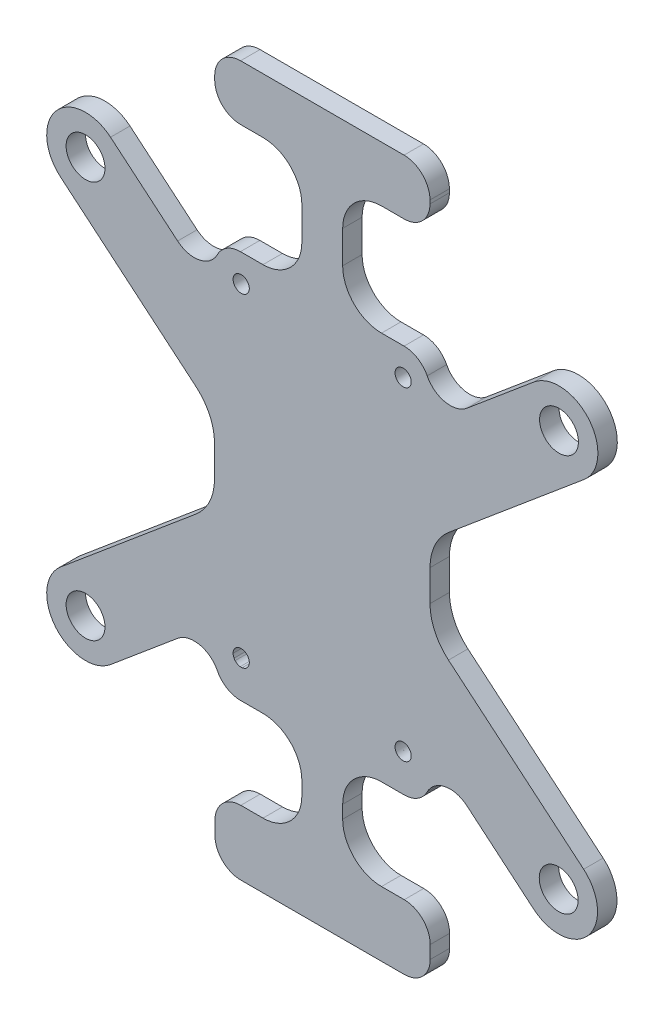
from build123d import *

# Parameters (mm, degrees)
SKETCH2_R           = 3
BOSS_EXTRUDE1_DEPTH = 3
FILLET1_R           = 4


with BuildPart() as part:
    # Sketch2 → Boss-Extrude1 (new body)
    with BuildSketch(Plane(origin=(0, 0, 68.235245174), x_dir=(-1, 0, 0), z_dir=(0, 0, -1))):
        with BuildLine():
            ThreePointArc((200.8599001, 75.914500352), (202.617259412, 80.157141039), (206.8599001, 81.914500352))
            Line((206.8599001, 81.914500352), (210.318399578, 81.914500352))
            ThreePointArc((210.318399578, 81.914500352), (213.146826703, 83.086073227), (214.318399578, 85.914500352))
            Line((214.318399578, 85.914500352), (214.318399578, 86.448569062))
            ThreePointArc((214.318399578, 86.448569062), (213.146826703, 89.276996187), (210.318399578, 90.448569062))
            Line((210.318399578, 90.448569062), (185.082704853, 90.448569062))
            ThreePointArc((185.082704853, 90.448569062), (182.254277728, 89.276996187), (181.082704853, 86.448569062))
            Line((181.082704853, 86.448569062), (181.082704853, 85.914500352))
            ThreePointArc((181.082704853, 85.914500352), (182.254277728, 83.086073227), (185.082704853, 81.914500352))
            Line((185.082704853, 81.914500352), (188.558928324, 81.914500352))
            ThreePointArc((188.558928324, 81.914500352), (192.801569011, 80.157141039), (194.558928324, 75.914500352))
            Line((194.558928324, 75.914500352), (194.558928324, 70.914500352))
            ThreePointArc((194.558928324, 70.914500352), (192.801569011, 66.671859665), (188.558928324, 64.914500352))
            Line((188.558928324, 64.914500352), (185.076777298, 64.914500352))
            ThreePointArc((185.076777298, 64.914500352), (182.248350173, 63.742927477), (181.076777298, 60.914500352))
            Line((181.076777298, 60.914500352), (181.076777298, 56.686920612))
            Line((181.076777298, 56.686920612), (165.01232587, 70.156152413))
            ThreePointArc((165.01232587, 70.156152413), (156.559616389, 69.413385675), (157.302383127, 60.960676194))
            Line((157.302383127, 60.960676194), (178.216739127, 43.425044169))
            ThreePointArc((178.216739127, 43.425044169), (180.326594352, 40.677056165), (181.076777298, 37.294726689))
            Line((181.076777298, 37.294726689), (181.076777298, 32.487814398))
            ThreePointArc((181.076777298, 32.487814398), (180.328083004, 29.108677592), (178.222135908, 26.362025896))
            Line((178.222135908, 26.362025896), (157.352338412, 8.832430774))
            ThreePointArc((157.352338412, 8.832430774), (156.617015993, 0.37907044), (165.070376328, -0.356251978))
            Line((165.070376328, -0.356251978), (181.076777298, 13.088331201))
            Line((181.076777298, 13.088331201), (181.076777298, 11.930427072))
            Line((181.076777298, 11.930427072), (181.076777298, 8.914500352))
            ThreePointArc((181.076777298, 8.914500352), (182.248350173, 6.086073227), (185.076777298, 4.914500352))
            Line((185.076777298, 4.914500352), (188.558928324, 4.914500352))
            ThreePointArc((188.558928324, 4.914500352), (192.801569011, 3.157141039), (194.558928324, -1.085499648))
            Line((194.558928324, -1.085499648), (194.558928324, -3.085499648))
            ThreePointArc((194.558928324, -3.085499648), (192.801569011, -7.328140335), (188.558928324, -9.085499648))
            Line((188.558928324, -9.085499648), (185.047198195, -9.085499648))
            ThreePointArc((185.047198195, -9.085499648), (182.21877107, -10.257072523), (181.047198195, -13.085499648))
            Line((181.047198195, -13.085499648), (181.047198195, -15.085499648))
            ThreePointArc((181.047198195, -15.085499648), (182.21877107, -17.913926773), (185.047198195, -19.085499648))
            Line((185.047198195, -19.085499648), (210.282892919, -19.085499648))
            ThreePointArc((210.282892919, -19.085499648), (213.111320044, -17.913926773), (214.282892919, -15.085499648))
            Line((214.282892919, -15.085499648), (214.282892919, -13.085499648))
            ThreePointArc((214.282892919, -13.085499648), (213.111320044, -10.257072523), (210.282892919, -9.085499648))
            Line((210.282892919, -9.085499648), (206.8599001, -9.085499648))
            ThreePointArc((206.8599001, -9.085499648), (202.617259412, -7.328140335), (200.8599001, -3.085499648))
            Line((200.8599001, -3.085499648), (200.8599001, -1.085499648))
            ThreePointArc((200.8599001, -1.085499648), (202.617259412, 3.157141039), (206.8599001, 4.914500352))
            Line((206.8599001, 4.914500352), (210.342051126, 4.914500352))
            ThreePointArc((210.342051126, 4.914500352), (213.170478251, 6.086073227), (214.342051126, 8.914500352))
            Line((214.342051126, 8.914500352), (214.342051126, 11.930427072))
            Line((214.342051126, 11.930427072), (214.342051126, 13.135793187))
            Line((214.342051126, 13.135793187), (230.399402266, -0.32748538))
            ThreePointArc((230.399402266, -0.32748538), (238.852111747, 0.415281358), (238.109345009, 8.867990839))
            Line((238.109345009, 8.867990839), (217.202089297, 26.397669631))
            ThreePointArc((217.202089297, 26.397669631), (215.092234072, 29.145657634), (214.342051126, 32.52798711))
            Line((214.342051126, 32.52798711), (214.342051126, 37.301480569))
            ThreePointArc((214.342051126, 37.301480569), (215.09074542, 40.680617376), (217.196692515, 43.427269071))
            Line((217.196692515, 43.427269071), (238.113392595, 60.996260038))
            ThreePointArc((238.113392595, 60.996260038), (238.848715014, 69.449620372), (230.39535468, 70.184942791))
            Line((230.39535468, 70.184942791), (214.342051126, 56.700963767))
            Line((214.342051126, 56.700963767), (214.342051126, 60.914500352))
            ThreePointArc((214.342051126, 60.914500352), (213.170478251, 63.742927477), (210.342051126, 64.914500352))
            Line((210.342051126, 64.914500352), (206.8599001, 64.914500352))
            ThreePointArc((206.8599001, 64.914500352), (202.617259412, 66.671859665), (200.8599001, 70.914500352))
            Line((200.8599001, 70.914500352), (200.8599001, 75.914500352))
        make_face()
        with Locations((161.21135737, 4.238089398)):
            Circle(SKETCH2_R, mode=Mode.SUBTRACT)
        with BuildLine():
            ThreePointArc((185.934292771, 11.679915797), (186.053113792, 11.586823557), (186.159847502, 11.480087831))
            ThreePointArc((186.159847502, 11.480087831), (186.252935887, 11.361267382), (186.331023692, 11.232092921))
            ThreePointArc((186.331023692, 11.232092921), (186.392973368, 11.09444513), (186.437879802, 10.950333754))
            ThreePointArc((186.437879802, 10.950333754), (186.465087989, 10.801861649), (186.474201683, 10.651192502))
            ThreePointArc((186.474201683, 10.651192502), (186.465087553, 10.500519764), (186.437878071, 10.352044225))
            ThreePointArc((186.437878071, 10.352044225), (186.392969746, 10.207930322), (186.331017561, 10.0702804))
            ThreePointArc((186.331017561, 10.0702804), (186.252930555, 9.941109897), (186.159843804, 9.822292998))
            ThreePointArc((186.159843804, 9.822292998), (186.053110121, 9.715558193), (185.934289288, 9.622466802))
            ThreePointArc((185.934289288, 9.622466802), (185.805115307, 9.544376995), (185.667470605, 9.482426437))
            ThreePointArc((185.667470605, 9.482426437), (185.523353139, 9.43751622), (185.374872981, 9.410305666))
            ThreePointArc((185.374872981, 9.410305666), (185.224200783, 9.401191602), (185.073528586, 9.410305666))
            ThreePointArc((185.073528586, 9.410305666), (184.925061955, 9.437512885), (184.780957016, 9.482416556))
            ThreePointArc((184.780957016, 9.482416556), (184.643309455, 9.544364821), (184.514132464, 9.62245287))
            ThreePointArc((184.514132464, 9.62245287), (184.395308021, 9.715543509), (184.288570868, 9.822278205))
            ThreePointArc((184.288570868, 9.822278205), (184.195478591, 9.941098916), (184.117387224, 10.070274268))
            ThreePointArc((184.117387224, 10.070274268), (184.055433048, 10.207927085), (184.010523496, 10.352044225))
            ThreePointArc((184.010523496, 10.352044225), (183.983314014, 10.500519764), (183.974199884, 10.651192502))
            ThreePointArc((183.974199884, 10.651192502), (183.983313578, 10.801861649), (184.010521765, 10.950333754))
            ThreePointArc((184.010521765, 10.950333754), (184.055429426, 11.094448368), (184.117381092, 11.232099052))
            ThreePointArc((184.117381092, 11.232099052), (184.19547326, 11.361278363), (184.28856717, 11.480102624))
            ThreePointArc((184.28856717, 11.480102624), (184.39530435, 11.586838242), (184.51412898, 11.679929729))
            ThreePointArc((184.51412898, 11.679929729), (184.643306412, 11.758018585), (184.780954545, 11.819967511))
            ThreePointArc((184.780954545, 11.819967511), (184.925059801, 11.864871587), (185.073526803, 11.89207912))
            ThreePointArc((185.073526803, 11.89207912), (185.224200783, 11.901193401), (185.374874764, 11.89207912))
            ThreePointArc((185.374874764, 11.89207912), (185.523355294, 11.864868252), (185.667473076, 11.819957629))
            ThreePointArc((185.667473076, 11.819957629), (185.80511835, 11.758006411), (185.934292771, 11.679915797))
        make_face(mode=Mode.SUBTRACT)
        with Locations((234.254373637, 4.27025273)):
            Circle(SKETCH2_R, mode=Mode.SUBTRACT)
        with BuildLine():
            ThreePointArc((209.010536826, 10.352046042), (208.983327509, 10.500520678), (208.974213434, 10.651192502))
            ThreePointArc((208.974213434, 10.651192502), (208.983327073, 10.801860734), (209.010535095, 10.950331938))
            ThreePointArc((209.010535095, 10.950331938), (209.055441255, 11.094442439), (209.117390555, 11.232089393))
            ThreePointArc((209.117390555, 11.232089393), (209.195480693, 11.361267136), (209.288572259, 11.480090194))
            ThreePointArc((209.288572259, 11.480090194), (209.395307056, 11.586825218), (209.51412916, 11.679916516))
            ThreePointArc((209.51412916, 11.679916516), (209.64331047, 11.758009014), (209.780963197, 11.819960414))
            ThreePointArc((209.780963197, 11.819960414), (209.925067578, 11.864864217), (210.073533678, 11.892071586))
            ThreePointArc((210.073533678, 11.892071586), (210.224206744, 11.901185811), (210.374879809, 11.892071586))
            ThreePointArc((210.374879809, 11.892071586), (210.523352674, 11.86486255), (210.667463317, 11.819955473))
            ThreePointArc((210.667463317, 11.819955473), (210.805109186, 11.758005777), (210.934284327, 11.679916516))
            ThreePointArc((210.934284327, 11.679916516), (211.05311013, 11.586821942), (211.159847781, 11.480082798))
            ThreePointArc((211.159847781, 11.480082798), (211.252935601, 11.36126307), (211.331022932, 11.232089393))
            ThreePointArc((211.331022932, 11.232089393), (211.392972232, 11.094442439), (211.437878393, 10.950331938))
            ThreePointArc((211.437878393, 10.950331938), (211.465086414, 10.801860734), (211.474200053, 10.651192502))
            ThreePointArc((211.474200053, 10.651192502), (211.465085978, 10.500520678), (211.437876661, 10.352046042))
            ThreePointArc((211.437876661, 10.352046042), (211.39296861, 10.207933014), (211.3310168, 10.070283927))
            ThreePointArc((211.3310168, 10.070283927), (211.252930269, 9.941114209), (211.159844083, 9.822298031))
            ThreePointArc((211.159844083, 9.822298031), (211.053106459, 9.715559809), (210.934280844, 9.622466083))
            ThreePointArc((210.934280844, 9.622466083), (210.805106142, 9.544377629), (210.667460847, 9.482428593))
            ThreePointArc((210.667460847, 9.482428593), (210.523350519, 9.437521922), (210.374878026, 9.410313201))
            ThreePointArc((210.374878026, 9.410313201), (210.224206744, 9.401199192), (210.073535461, 9.410313201))
            ThreePointArc((210.073535461, 9.410313201), (209.925069732, 9.437520255), (209.780965668, 9.482423653))
            ThreePointArc((209.780965668, 9.482423653), (209.643313514, 9.544374392), (209.514132643, 9.622466083))
            ThreePointArc((209.514132643, 9.622466083), (209.395310727, 9.715556533), (209.288575957, 9.822290635))
            ThreePointArc((209.288575957, 9.822290635), (209.195486025, 9.941110143), (209.117396687, 10.070283927))
            ThreePointArc((209.117396687, 10.070283927), (209.055444877, 10.207933014), (209.010536826, 10.352046042))
        make_face(mode=Mode.SUBTRACT)
        with BuildLine():
            ThreePointArc((186.437878956, 60.352041027), (186.392972747, 60.207931469), (186.331023711, 60.070285367))
            ThreePointArc((186.331023711, 60.070285367), (186.252935112, 59.941109757), (186.159845668, 59.822288366))
            ThreePointArc((186.159845668, 59.822288366), (186.053111971, 59.715553098), (185.934291042, 59.622461282))
            ThreePointArc((185.934291042, 59.622461282), (185.805116838, 59.54437107), (185.667471848, 59.48242018))
            ThreePointArc((185.667471848, 59.48242018), (185.523354439, 59.437509813), (185.37487432, 59.410299102))
            ThreePointArc((185.37487432, 59.410299102), (185.224200783, 59.401184876), (185.073527246, 59.410299102))
            ThreePointArc((185.073527246, 59.410299102), (184.925060655, 59.437506479), (184.780955773, 59.482410299))
            ThreePointArc((184.780955773, 59.482410299), (184.643307924, 59.544358896), (184.51413071, 59.622447349))
            ThreePointArc((184.51413071, 59.622447349), (184.395306171, 59.715538414), (184.288569003, 59.822273573))
            ThreePointArc((184.288569003, 59.822273573), (184.195474034, 59.941098775), (184.117381074, 60.070279236))
            ThreePointArc((184.117381074, 60.070279236), (184.055430047, 60.207928231), (184.01052261, 60.352041027))
            ThreePointArc((184.01052261, 60.352041027), (183.983313775, 60.500514851), (183.974199863, 60.651185796))
            ThreePointArc((183.974199863, 60.651185796), (183.983313775, 60.801856741), (184.01052261, 60.950330565))
            ThreePointArc((184.01052261, 60.950330565), (184.055431217, 61.094446445), (184.11738414, 61.232098198))
            ThreePointArc((184.11738414, 61.232098198), (184.195475908, 61.361275532), (184.288569003, 61.480098019))
            ThreePointArc((184.288569003, 61.480098019), (184.395307755, 61.586834582), (184.514134193, 61.679926648))
            ThreePointArc((184.514134193, 61.679926648), (184.643310382, 61.758013987), (184.780957008, 61.819961762))
            ThreePointArc((184.780957008, 61.819961762), (184.925061514, 61.864865325), (185.073527692, 61.892072544))
            ThreePointArc((185.073527692, 61.892072544), (185.224200783, 61.901186717), (185.374873875, 61.892072544))
            ThreePointArc((185.374873875, 61.892072544), (185.52335358, 61.864861991), (185.667470613, 61.81995188))
            ThreePointArc((185.667470613, 61.81995188), (185.80511438, 61.758001813), (185.934287558, 61.679912715))
            ThreePointArc((185.934287558, 61.679912715), (186.053110387, 61.586819897), (186.159845668, 61.480083227))
            ThreePointArc((186.159845668, 61.480083227), (186.252933238, 61.36126455), (186.331020645, 61.232092066))
            ThreePointArc((186.331020645, 61.232092066), (186.392971577, 61.094443208), (186.437878956, 60.950330565))
            ThreePointArc((186.437878956, 60.950330565), (186.465087792, 60.801856741), (186.474201704, 60.651185796))
            ThreePointArc((186.474201704, 60.651185796), (186.465087792, 60.500514851), (186.437878956, 60.352041027))
        make_face(mode=Mode.SUBTRACT)
        with Locations((161.157354498, 65.558414303)):
            Circle(SKETCH2_R, mode=Mode.SUBTRACT)
        with BuildLine():
            ThreePointArc((209.780962969, 61.819961762), (209.925067475, 61.864865325), (210.073533652, 61.892072544))
            ThreePointArc((210.073533652, 61.892072544), (210.224206744, 61.901186717), (210.374879835, 61.892072544))
            ThreePointArc((210.374879835, 61.892072544), (210.523352777, 61.864863658), (210.667463546, 61.819956821))
            ThreePointArc((210.667463546, 61.819956821), (210.805108742, 61.7580079), (210.934283426, 61.679919681))
            ThreePointArc((210.934283426, 61.679919681), (211.053111757, 61.586823963), (211.159851629, 61.480083227))
            ThreePointArc((211.159851629, 61.480083227), (211.252939199, 61.36126455), (211.331026605, 61.232092066))
            ThreePointArc((211.331026605, 61.232092066), (211.392977538, 61.094443208), (211.437884917, 60.950330565))
            ThreePointArc((211.437884917, 60.950330565), (211.465093752, 60.801856741), (211.474207664, 60.651185796))
            ThreePointArc((211.474207664, 60.651185796), (211.465093752, 60.500514851), (211.437884917, 60.352041027))
            ThreePointArc((211.437884917, 60.352041027), (211.392978707, 60.207931469), (211.331029671, 60.070285367))
            ThreePointArc((211.331029671, 60.070285367), (211.252941073, 59.941109757), (211.159851629, 59.822288366))
            ThreePointArc((211.159851629, 59.822288366), (211.053113341, 59.715549032), (210.934286909, 59.622454315))
            ThreePointArc((210.934286909, 59.622454315), (210.805111201, 59.544364983), (210.667464781, 59.48241524))
            ThreePointArc((210.667464781, 59.48241524), (210.523353636, 59.437508146), (210.374880281, 59.410299102))
            ThreePointArc((210.374880281, 59.410299102), (210.224206744, 59.401184876), (210.073533206, 59.410299102))
            ThreePointArc((210.073533206, 59.410299102), (209.925066615, 59.437506479), (209.780961734, 59.482410299))
            ThreePointArc((209.780961734, 59.482410299), (209.643308455, 59.544361745), (209.514126578, 59.622454315))
            ThreePointArc((209.514126578, 59.622454315), (209.395303844, 59.715545756), (209.288568411, 59.822280969))
            ThreePointArc((209.288568411, 59.822280969), (209.195475221, 59.941105691), (209.117383816, 60.070285367))
            ThreePointArc((209.117383816, 60.070285367), (209.05543478, 60.207931469), (209.01052857, 60.352041027))
            ThreePointArc((209.01052857, 60.352041027), (208.983319735, 60.500514851), (208.974205823, 60.651185796))
            ThreePointArc((208.974205823, 60.651185796), (208.983319735, 60.801856741), (209.01052857, 60.950330565))
            ThreePointArc((209.01052857, 60.950330565), (209.05543595, 61.094443208), (209.117386882, 61.232092066))
            ThreePointArc((209.117386882, 61.232092066), (209.195477095, 61.361268616), (209.288568411, 61.480090623))
            ThreePointArc((209.288568411, 61.480090623), (209.395305428, 61.586827239), (209.514130061, 61.679919681))
            ThreePointArc((209.514130061, 61.679919681), (209.643310913, 61.758011137), (209.780962969, 61.819961762))
        make_face(mode=Mode.SUBTRACT)
        with Locations((234.254373637, 65.590601414)):
            Circle(SKETCH2_R, mode=Mode.SUBTRACT)
    extrude(amount=BOSS_EXTRUDE1_DEPTH)

    # Fillet1
    fillet1_edges = [part.edges().sort_by_distance(p)[0] for p in [
        (-181.076777298, 13.088331201, 66.735245174),
        (-214.342051126, 13.135793187, 66.735245174),
        (-214.342051126, 56.700963767, 66.735245174),
        (-181.076777298, 56.686920612, 66.735245174),
    ]]
    fillet(fillet1_edges, radius=FILLET1_R)


solid = part.part
